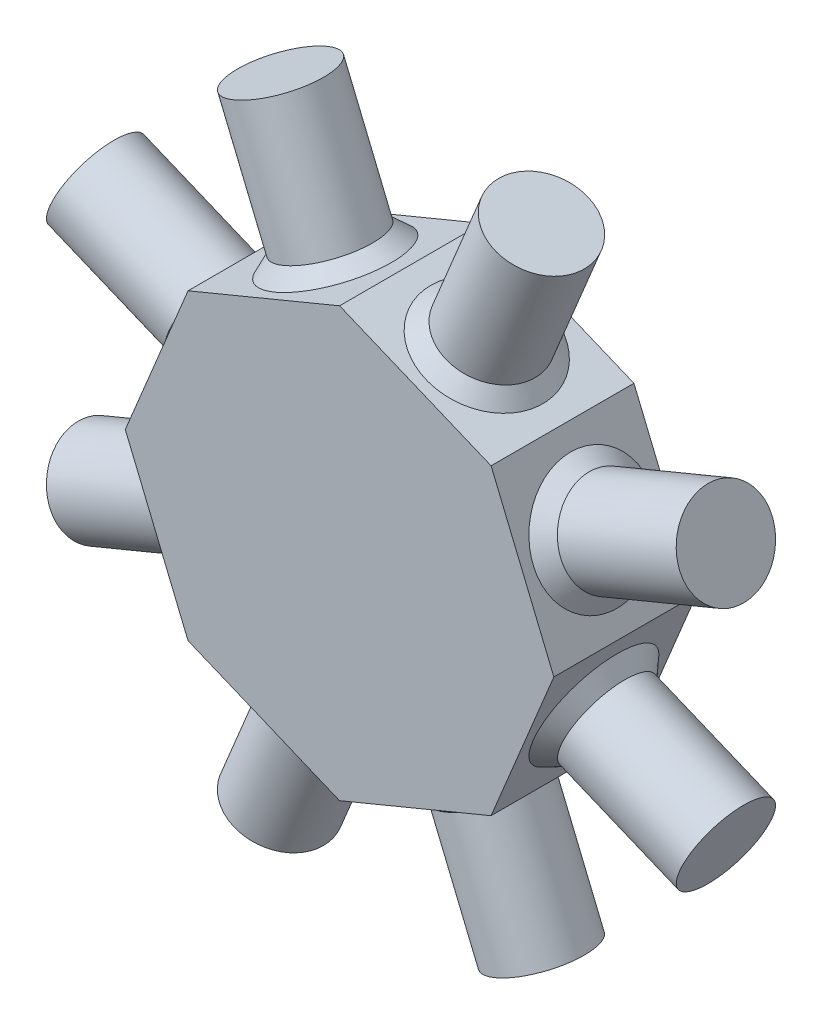
from build123d import *

# Parameters (mm, degrees)
SKETCH1_R           = 38.1
BOSS_EXTRUDE1_DEPTH = 12.7
SKETCH2_OUTSIDE_W   = 100.344
SKETCH2_OUTSIDE_H   = 100.344
CUT_EXTRUDE1_DEPTH  = 25.4
SKETCH3_R           = 8.255
BOSS_EXTRUDE2_DEPTH = 25.4
CIRPATTERN4_COUNT   = 8
CHAMFER2_SIZE       = 2.54


with BuildPart() as part:
    # Sketch1 → Boss-Extrude1 (new body, symmetric)
    with BuildSketch(Plane.XY):
        Circle(SKETCH1_R)
    extrude(amount=BOSS_EXTRUDE1_DEPTH, both=True)

    # Sketch2 outside → Cut-Extrude1 (cut)
    with BuildSketch(Plane.XY.offset(12.7)):
        Rectangle(SKETCH2_OUTSIDE_W, SKETCH2_OUTSIDE_H)
        Polygon((38.1, 0), (26.940768363, 26.940768363), (0, 38.1), (-26.940768363, 26.940768363), (-38.1, 0), (-26.940768363, -26.940768363), (0, -38.1), (26.940768363, -26.940768363), align=None, mode=Mode.SUBTRACT)
    extrude(amount=-CUT_EXTRUDE1_DEPTH, mode=Mode.SUBTRACT)

    # Sketch3 → Boss-Extrude2 (add)
    with BuildSketch(Plane(origin=(13.470384182, 32.520384182, 0), x_dir=(0.923879533, -0.382683432, 0), z_dir=(0.382683432, 0.923879533, 0))):
        Circle(SKETCH3_R)
    boss_extrude2 = extrude(amount=BOSS_EXTRUDE2_DEPTH)

    # CirPattern4: Boss-Extrude2 ×8 about axis
    cirpattern4_axis = Axis((0, 0, 0), (0, 0, 1))
    for i in range(1, CIRPATTERN4_COUNT):
        add(boss_extrude2.rotate(cirpattern4_axis, i * 360 / CIRPATTERN4_COUNT))

    # Chamfer2
    chamfer2_edges = [part.edges().sort_by_distance(p)[0] for p in [
        (5.843758641, 35.679435916, 0),
        (29.361332447, 21.097009722, 0),
        (35.679435916, -5.843758641, 0),
        (21.097009722, -29.361332447, 0),
        (-5.843758641, -35.679435916, 0),
        (-29.361332447, -21.097009722, 0),
        (-35.679435916, 5.843758641, 0),
        (-21.097009722, 29.361332447, 0),
    ]]
    chamfer(chamfer2_edges, length=CHAMFER2_SIZE)


solid = part.part
